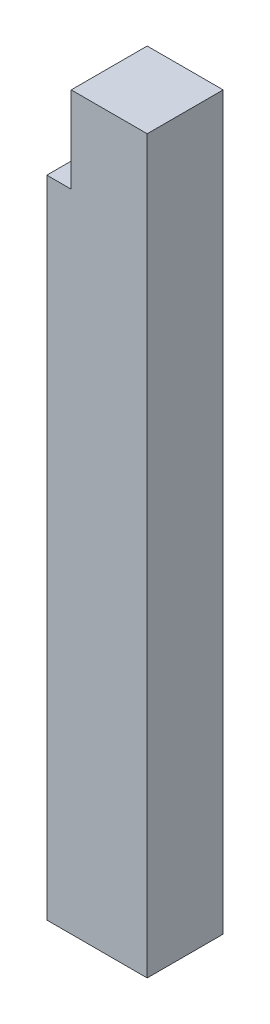
from build123d import *

# Parameters (mm, degrees)
BOSS_EXTRUDE2_DEPTH = 45
SKETCH3_W           = 5.3
SKETCH3_H           = 5.3
BOSS_EXTRUDE3_DEPTH = 6


with BuildPart() as part:
    # Sketch2 → Boss-Extrude2 (new body)
    with BuildSketch(Plane(origin=(0, 0, 0), x_dir=(1, 0, 0), z_dir=(0, 1, 0))):
        Polygon((-3.429137356, 0.875), (-3.429137356, 2.703653145), (3.570862644, 2.703653145), (3.570862644, -2.596346855), (-3.429137356, -2.596346855), (-3.429137356, -0.875), (0.959612499, -0.875), (0.959612499, 0.875), align=None)
    extrude(amount=BOSS_EXTRUDE2_DEPTH)

    # Sketch3 → Boss-Extrude3 (add)
    with BuildSketch(Plane(origin=(0, 45, 0), x_dir=(1, 0, 0), z_dir=(0, 1, 0))):
        with Locations((0.920862644, 0.053653145)):
            Rectangle(SKETCH3_W, SKETCH3_H)
    extrude(amount=BOSS_EXTRUDE3_DEPTH)


solid = part.part
